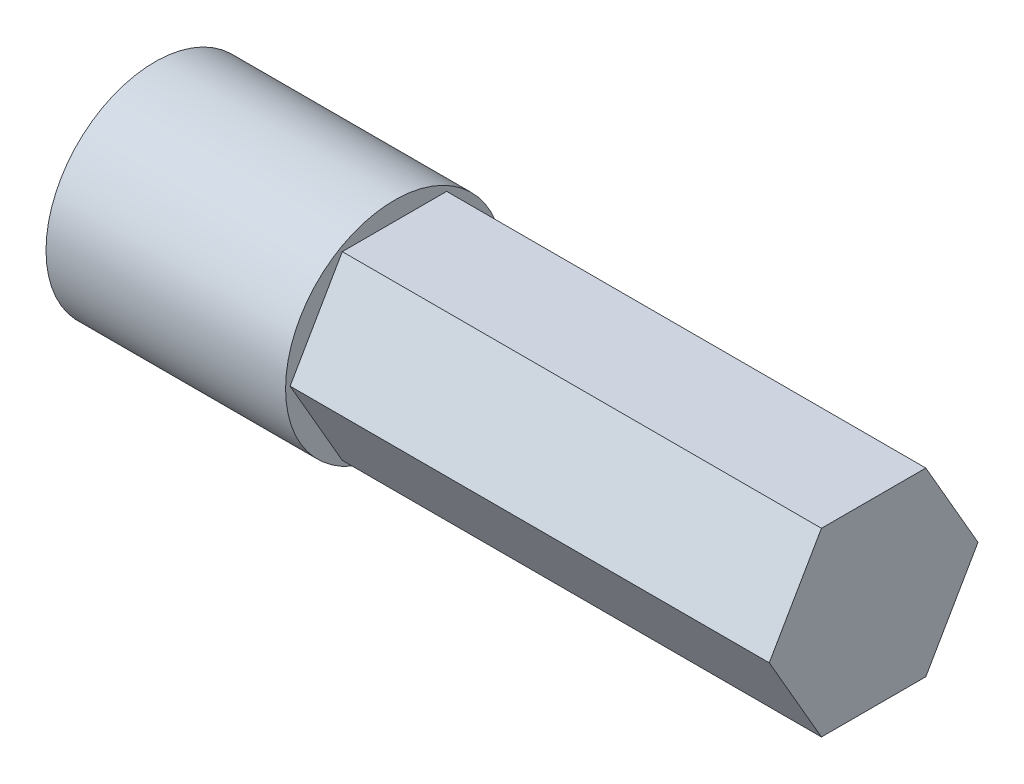
from build123d import *

# Parameters (mm, degrees)
BOSS_EXTRUDE1_DEPTH = 22
SKETCH2_R           = 5
BOSS_EXTRUDE2_DEPTH = 11
SKETCH3_R           = 3
CUT_EXTRUDE1_DEPTH  = 11


with BuildPart() as part:
    # Sketch1 → Boss-Extrude1 (new body)
    with BuildSketch(Plane(origin=(0, 0, 0), x_dir=(0, 0, -1), z_dir=(1, 0, 0))):
        Polygon((2.396003617, -4.15), (4.792007234, 0), (2.396003617, 4.15), (-2.396003617, 4.15), (-4.792007234, 0), (-2.396003617, -4.15), align=None)
    extrude(amount=BOSS_EXTRUDE1_DEPTH)

    # Sketch2 → Boss-Extrude2 (add)
    with BuildSketch(Plane.ZY):
        Circle(SKETCH2_R)
    extrude(amount=BOSS_EXTRUDE2_DEPTH)

    # Sketch3 → Cut-Extrude1 (cut)
    with BuildSketch(Plane.ZY.offset(11)):
        Circle(SKETCH3_R)
    extrude(amount=-CUT_EXTRUDE1_DEPTH, mode=Mode.SUBTRACT)


solid = part.part
